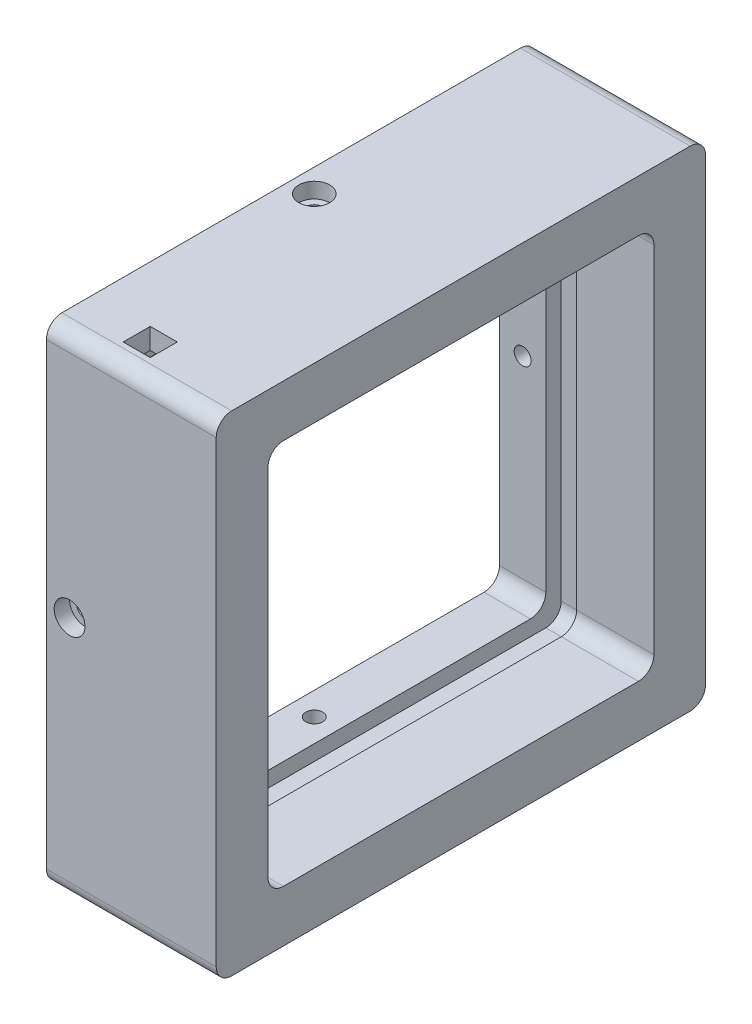
from build123d import *

# Parameters (mm, degrees)
SKETCH_1_W           = 63.4
SKETCH_1_H           = 63.4
EXTRUDE_1_DEPTH      = 22
SKETCH_2_W           = 50
SKETCH_2_H           = 50
CUT_EXTRUDE_1_DEPTH  = 10
SKETCH_3_W           = 54
SKETCH_3_H           = 54
CUT_EXTRUDE_2_DEPTH  = 12
SKETCH_4_W           = 6
SKETCH_4_H           = 54
CUT_EXTRUDE_3_DEPTH  = 2
SKETCH_5_W           = 6
SKETCH_5_H           = 56
CUT_EXTRUDE_4_DEPTH  = 2
SKETCH_6_W           = 6
SKETCH_6_H           = 56
CUT_EXTRUDE_5_DEPTH  = 2
SKETCH_8_W           = 6
SKETCH_8_H           = 58
CUT_EXTRUDE_9_DEPTH  = 2
CUT_EXTRUDE_11_REACH = 4.7
SKETCH_9_W           = 3.5
SKETCH_9_H           = 3.5
SKETCH_10_R          = 2
CUT_EXTRUDE_12_DEPTH = 2
CUT_EXTRUDE_13_REACH = 63.4
SKETCH_11_R          = 1.1
SKETCH_12_R          = 2
CUT_EXTRUDE_14_DEPTH = 2
CUT_EXTRUDE_15_REACH = 65.4
SKETCH_13_R          = 1.1
SKETCH_14_R          = 2
CUT_EXTRUDE_16_DEPTH = 2
CUT_EXTRUDE_17_REACH = 63.4
SKETCH_15_R          = 1.1
SKETCH_16_R          = 2
CUT_EXTRUDE_18_DEPTH = 2
CUT_EXTRUDE_19_REACH = 63.4
SKETCH_17_R          = 1.1
FILLET_1_R           = 2
FILLET_2_R           = 2
FILLET_3_R           = 2
FILLET_4_R           = 2


with BuildPart() as part:
    # 草图1 → 凸台-拉伸1 (new body)
    with BuildSketch(Plane(origin=(0, 0, 0), x_dir=(0, 0, -1), z_dir=(1, 0, 0))):
        Rectangle(SKETCH_1_W, SKETCH_1_H)
    extrude(amount=EXTRUDE_1_DEPTH)

    # 草图2 → 切除-拉伸1 (cut)
    with BuildSketch(Plane(origin=(22, 0, 0), x_dir=(0, 0, -1), z_dir=(1, 0, 0))):
        Rectangle(SKETCH_2_W, SKETCH_2_H)
    extrude(amount=-CUT_EXTRUDE_1_DEPTH, mode=Mode.SUBTRACT)

    # 草图3 → 切除-拉伸2 (cut)
    with BuildSketch(Plane.ZY):
        Rectangle(SKETCH_3_W, SKETCH_3_H)
    extrude(amount=-CUT_EXTRUDE_2_DEPTH, mode=Mode.SUBTRACT)

    # 草图4 → 切除-拉伸3 (cut)
    with BuildSketch(Plane(origin=(0, 27, 0), x_dir=(-1, 0, 0), z_dir=(0, -1, 0))):
        with Locations((-9, 0)):
            Rectangle(SKETCH_4_W, SKETCH_4_H)
    extrude(amount=-CUT_EXTRUDE_3_DEPTH, mode=Mode.SUBTRACT)

    # 草图5 → 切除-拉伸4 (cut)
    with BuildSketch(Plane.XY.offset(-27)):
        with Locations((9, 1)):
            Rectangle(SKETCH_5_W, SKETCH_5_H)
    extrude(amount=-CUT_EXTRUDE_4_DEPTH, mode=Mode.SUBTRACT)

    # 草图6 → 切除-拉伸5 (cut)
    with BuildSketch(Plane(origin=(0, -27, 0), x_dir=(1, 0, 0), z_dir=(0, 1, 0))):
        with Locations((9, 1)):
            Rectangle(SKETCH_6_W, SKETCH_6_H)
    extrude(amount=-CUT_EXTRUDE_5_DEPTH, mode=Mode.SUBTRACT)

    # 草图8 → 切除-拉伸9 (cut)
    with BuildSketch(Plane(origin=(0, 0, 27), x_dir=(-1, 0, 0), z_dir=(0, 0, -1))):
        with Locations((-9, 0)):
            Rectangle(SKETCH_8_W, SKETCH_8_H)
    extrude(amount=-CUT_EXTRUDE_9_DEPTH, mode=Mode.SUBTRACT)

    # 草图9 → 切除-拉伸11 (cut, up to next)
    with BuildSketch(Plane(origin=(0, 29, 0), x_dir=(-1, 0, 0), z_dir=(0, -1, 0)), mode=Mode.PRIVATE) as cut_extrude_11_sk1:
        with Locations((-9, -27.25)):
            Rectangle(SKETCH_9_W, SKETCH_9_H)
    cut_extrude_11_tool1 = extrude(cut_extrude_11_sk1.sketch, amount=-CUT_EXTRUDE_11_REACH, mode=Mode.PRIVATE) & part.part
    add(cut_extrude_11_tool1.solids().sort_by_distance((9, 29, 27.25))[0], mode=Mode.SUBTRACT)

    # 草图10 → 切除-拉伸12 (cut)
    with BuildSketch(Plane(origin=(0, 0, -31.7), x_dir=(-1, 0, 0), z_dir=(0, 0, -1))):
        with Locations((-3, 0)):
            Circle(SKETCH_10_R)
    extrude(amount=-CUT_EXTRUDE_12_DEPTH, mode=Mode.SUBTRACT)

    # 草图11 → 切除-拉伸13 (cut, up to next)
    with BuildSketch(Plane(origin=(0, 0, -29.7), x_dir=(-1, 0, 0), z_dir=(0, 0, -1)), mode=Mode.PRIVATE) as cut_extrude_13_sk1:
        with Locations((-3, 0)):
            Circle(SKETCH_11_R)
    cut_extrude_13_tool1 = extrude(cut_extrude_13_sk1.sketch, amount=-CUT_EXTRUDE_13_REACH, mode=Mode.PRIVATE) & part.part
    add(cut_extrude_13_tool1.solids().sort_by_distance((3, 0, -29.7))[0], mode=Mode.SUBTRACT)

    # 草图12 → 切除-拉伸14 (cut)
    with BuildSketch(Plane.XY.offset(31.7)):
        with Locations((3, 0)):
            Circle(SKETCH_12_R)
    extrude(amount=-CUT_EXTRUDE_14_DEPTH, mode=Mode.SUBTRACT)

    # 草图13 → 切除-拉伸15 (cut, up to next)
    with BuildSketch(Plane.XY.offset(31.7), mode=Mode.PRIVATE) as cut_extrude_15_sk1:
        with Locations((3, 0)):
            Circle(SKETCH_13_R)
    cut_extrude_15_tool1 = extrude(cut_extrude_15_sk1.sketch, amount=-CUT_EXTRUDE_15_REACH, mode=Mode.PRIVATE) & part.part
    add(cut_extrude_15_tool1.solids().sort_by_distance((3, 0, 31.7))[0], mode=Mode.SUBTRACT)

    # 草图14 → 切除-拉伸16 (cut)
    with BuildSketch(Plane(origin=(0, -31.7, 0), x_dir=(-1, 0, 0), z_dir=(0, -1, 0))):
        with Locations((-3, 0)):
            Circle(SKETCH_14_R)
    extrude(amount=-CUT_EXTRUDE_16_DEPTH, mode=Mode.SUBTRACT)

    # 草图15 → 切除-拉伸17 (cut, up to next)
    with BuildSketch(Plane(origin=(0, -29.7, 0), x_dir=(-1, 0, 0), z_dir=(0, -1, 0)), mode=Mode.PRIVATE) as cut_extrude_17_sk1:
        with Locations((-3, 0)):
            Circle(SKETCH_15_R)
    cut_extrude_17_tool1 = extrude(cut_extrude_17_sk1.sketch, amount=-CUT_EXTRUDE_17_REACH, mode=Mode.PRIVATE) & part.part
    add(cut_extrude_17_tool1.solids().sort_by_distance((3, -29.7, 0))[0], mode=Mode.SUBTRACT)

    # 草图16 → 切除-拉伸18 (cut)
    with BuildSketch(Plane(origin=(0, 31.7, 0), x_dir=(1, 0, 0), z_dir=(0, 1, 0))):
        with Locations((3, 0)):
            Circle(SKETCH_16_R)
    extrude(amount=-CUT_EXTRUDE_18_DEPTH, mode=Mode.SUBTRACT)

    # 草图17 → 切除-拉伸19 (cut, up to next)
    with BuildSketch(Plane(origin=(0, 29.7, 0), x_dir=(1, 0, 0), z_dir=(0, 1, 0)), mode=Mode.PRIVATE) as cut_extrude_19_sk1:
        with Locations((3, 0)):
            Circle(SKETCH_17_R)
    cut_extrude_19_tool1 = extrude(cut_extrude_19_sk1.sketch, amount=-CUT_EXTRUDE_19_REACH, mode=Mode.PRIVATE) & part.part
    add(cut_extrude_19_tool1.solids().sort_by_distance((3, 29.7, 0))[0], mode=Mode.SUBTRACT)

    # 圆角1
    fillet_1_edges = [part.edges().sort_by_distance(p)[0] for p in [
        (9, -29, -29),
        (9, -29, 29),
        (9, 29, -29),
    ]]
    fillet(fillet_1_edges, radius=FILLET_1_R)

    # 圆角2
    fillet_2_edges = [part.edges().sort_by_distance(p)[0] for p in [
        (17, 25, -25),
        (17, -25, -25),
        (17, -25, 25),
        (17, 25, 25),
    ]]
    fillet(fillet_2_edges, radius=FILLET_2_R)

    # 圆角3
    fillet_3_edges = [part.edges().sort_by_distance(p)[0] for p in [
        (3, 27, -27),
        (3, 27, 27),
        (3, -27, -27),
        (3, -27, 27),
    ]]
    fillet(fillet_3_edges, radius=FILLET_3_R)

    # 圆角4
    fillet_4_edges = [part.edges().sort_by_distance(p)[0] for p in [
        (11, -31.7, -31.7),
        (11, -31.7, 31.7),
        (11, 31.7, 31.7),
        (11, 31.7, -31.7),
    ]]
    fillet(fillet_4_edges, radius=FILLET_4_R)


solid = part.part
